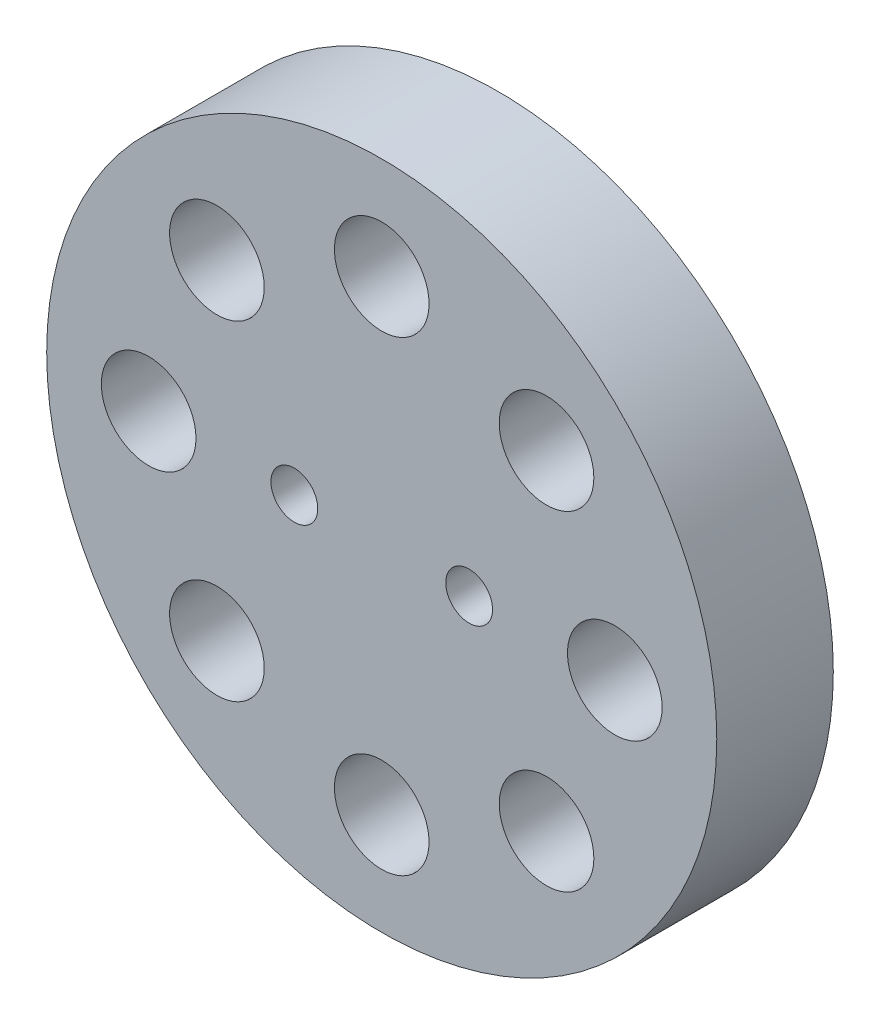
from build123d import *

# Parameters (mm, degrees)
SKETCH1_R                    = 36.5125
BOSS_EXTRUDE1_DEPTH          = 12.7
F_1_4_20_TAPPED_HOLE1_D      = 5.1054
F_3_8_0_375_DIAMETER_HOLE1_D = 10.3124
CIRPATTERN1_COUNT            = 8


with BuildPart() as part:
    # Sketch1 → Boss-Extrude1 (new body)
    with BuildSketch(Plane.XY):
        Circle(SKETCH1_R)
    extrude(amount=BOSS_EXTRUDE1_DEPTH)

    # 1_4-20 Tapped Hole1 (through all)
    with Locations(Plane.XY.offset(12.7)):
        with Locations((9.525, 0), (-9.525, 0)):
            Hole(F_1_4_20_TAPPED_HOLE1_D / 2)

    # 3_8 _0.375_ Diameter Hole1 (through all)
    with Locations(Plane.XY.offset(12.7)):
        with Locations((25.4, 0)):
            f_3_8_0_375_diameter_hole1 = Hole(F_3_8_0_375_DIAMETER_HOLE1_D / 2)

    # CirPattern1: 3_8 _0.375_ Diameter Hole1 ×8 about axis
    cirpattern1_axis = Axis((0, 0, 0), (0, 0, 1))
    for i in range(1, CIRPATTERN1_COUNT):
        add(f_3_8_0_375_diameter_hole1.rotate(cirpattern1_axis, i * 360 / CIRPATTERN1_COUNT), mode=Mode.SUBTRACT)


solid = part.part
